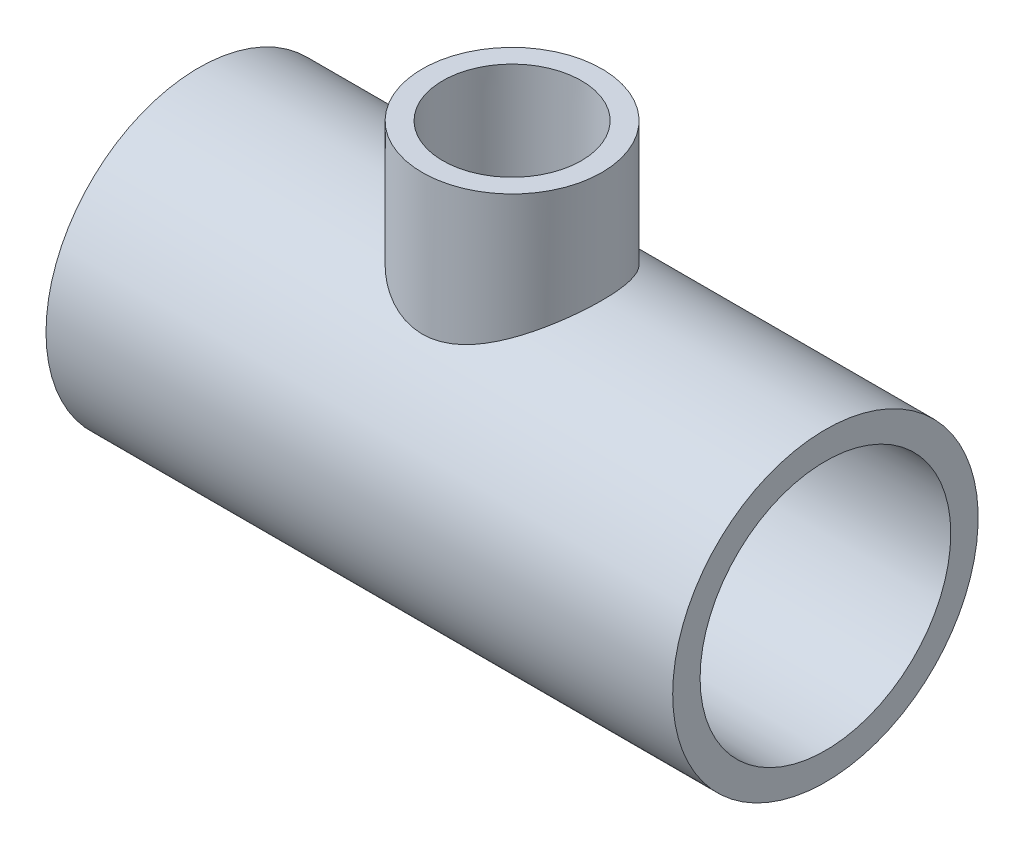
from build123d import *

# Parameters (mm, degrees)
SKETCH4_R           = 29.591
BOSS_EXTRUDE1_DEPTH = 51.816
SKETCH5_R           = 17.399
BOSS_EXTRUDE2_DEPTH = 25.4


with BuildPart() as part:
    # Sketch1 → Revolve1 (revolve)
    with BuildSketch(Plane.XY, mode=Mode.PRIVATE) as revolve1_sk:
        Polygon((-60.706, -29.591), (-25.908, -29.591), (-25.908, -24.0538), (-60.706, -24.2824), align=None)
        Polygon((60.706, -24.2824), (25.908, -24.0538), (25.908, -29.591), (60.706, -29.591), align=None)
    revolve(revolve1_sk.sketch.rotate(Axis((-60.706, 0, 0), (1, 0, 0)), 270), axis=Axis((-60.706, 0, 0), (1, 0, 0)))



with BuildPart() as body_2:
    # Sketch2 → Revolve2 (revolve)
    with BuildSketch(Plane.XY):
        Polygon((13.4366, 51.054), (13.2842, 25.4), (17.399, 25.4), (17.399, 51.054), align=None)
    revolve(axis=Axis((0, 0, 0), (0, 1, 0)))


with BuildPart() as part_1:
    add(part.part)

    add(body_2.part)  # Boss-Extrude1 merges body 2
    # Sketch4 → Boss-Extrude1 (add)
    with BuildSketch(Plane(origin=(-25.908, 0, 0), x_dir=(0, 0, -1), z_dir=(1, 0, 0))):
        with Locations(Location((0, 0, 0), (0, 0, 180))):
            Circle(SKETCH4_R)
    extrude(amount=BOSS_EXTRUDE1_DEPTH)

    # Sketch5 → Boss-Extrude2 (add)
    with BuildSketch(Plane.XZ.offset(-25.4)):
        Circle(SKETCH5_R)
    extrude(amount=BOSS_EXTRUDE2_DEPTH)

    # Sketch6 → Cut-Revolve1 (revolve, cut)
    with BuildSketch(Plane.XY, mode=Mode.PRIVATE) as cut_revolve1_sk:
        Polygon((-60.706, -24.2824), (-25.908, -24.0538), (-25.908, -19.05), (25.908, -19.05), (25.908, -24.0538), (60.706, -24.2824), (60.706, 0), (-60.706, 0), align=None)
    revolve(cut_revolve1_sk.sketch.rotate(Axis((60.706, 0, 0), (-1, 0, 0)), 270), axis=Axis((60.706, 0, 0), (-1, 0, 0)), mode=Mode.SUBTRACT)

    # Sketch7 → Cut-Revolve2 (revolve, cut)
    with BuildSketch(Plane.XY):
        Polygon((13.4366, 51.054), (13.2842, 25.4), (9.4234, 25.4), (9.4234, 0), (0, 0), (0, 51.054), align=None)
    revolve(axis=Axis((0, 0, 0), (0, 1, 0)), mode=Mode.SUBTRACT)


solid = part_1.part
